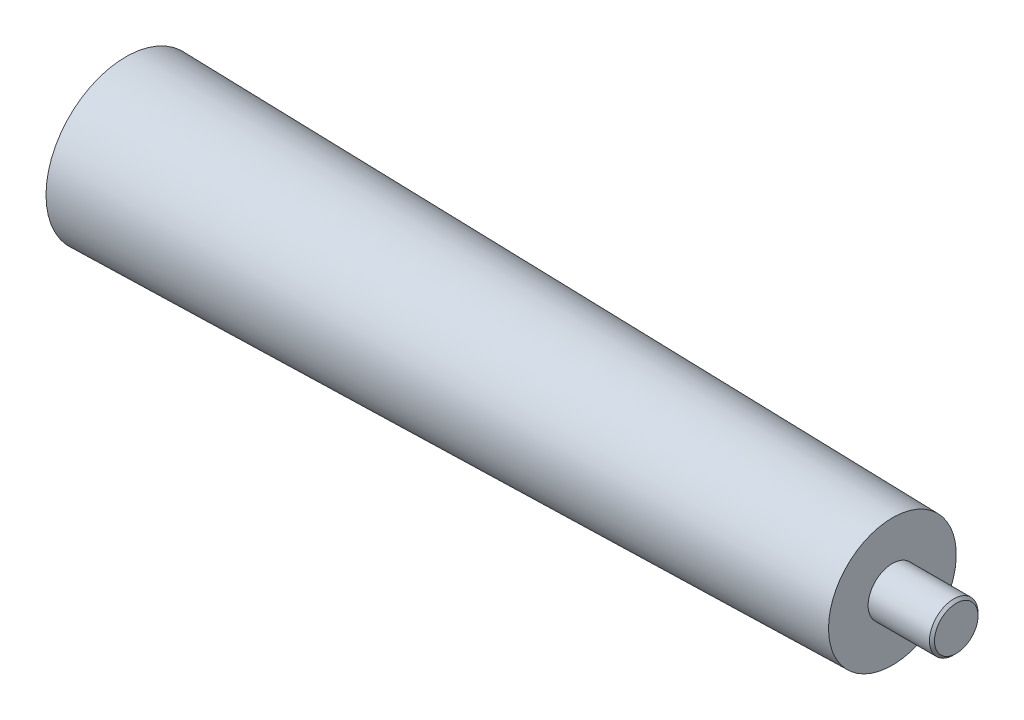
from build123d import *

# Parameters (mm, degrees)
CHAMFER1_SIZE = 0.5


with BuildPart() as part:
    # Sketch1 → Revolve1 (revolve)
    with BuildSketch(Plane(origin=(0, 0, 0), x_dir=(1, 0, 0), z_dir=(0, 1, 0))):
        Polygon((0, 0), (165.1, 0), (165.1, 4.83), (152.4, 4.83), (152.4, 12.7), (0, 15.88), align=None)
    revolve(axis=Axis((0, 0, 0), (1, 0, 0)))

    # Chamfer1
    chamfer1_edges = [part.edges().sort_by_distance(p)[0] for p in [
        (165.1, 0, 4.83),
    ]]
    chamfer(chamfer1_edges, length=CHAMFER1_SIZE)


solid = part.part
